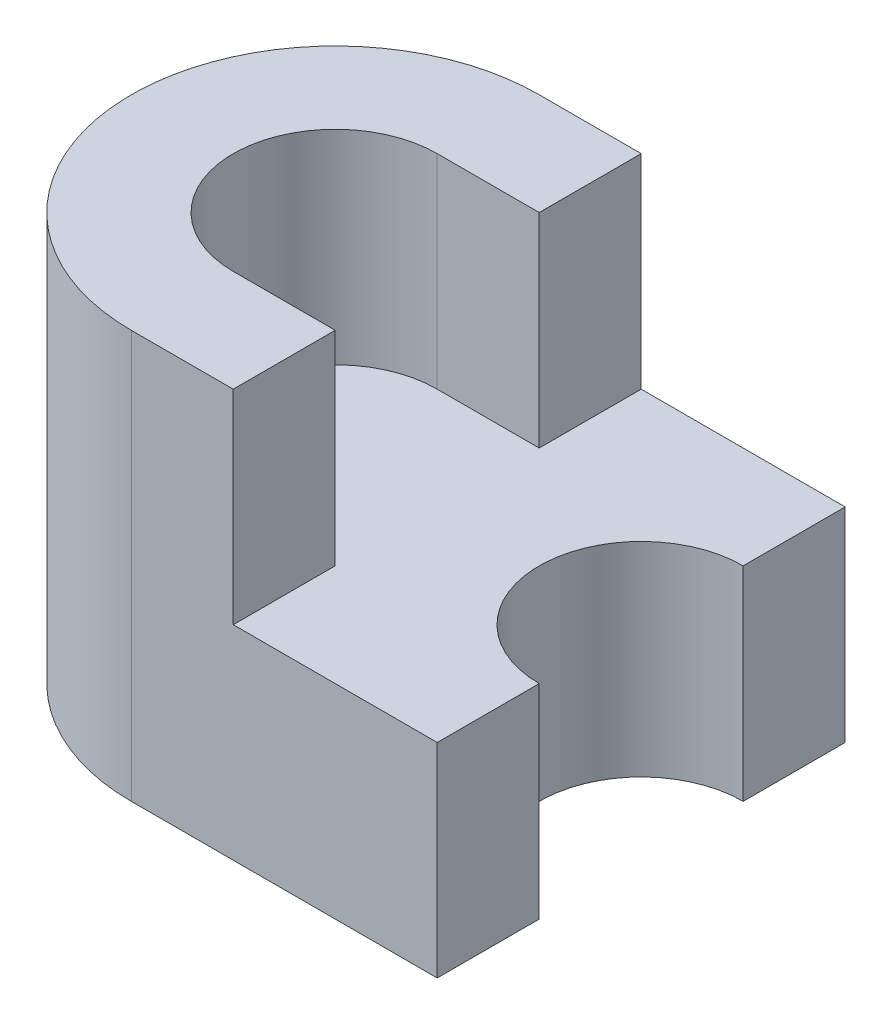
from build123d import *

# Parameters (mm, degrees)
EXTRUDE_1_DEPTH = 10
EXTRUDE_2_DEPTH = 20
SCALE_1_SCALE   = 0.2


with BuildPart() as part:
    # 草圖1 → 填料-伸長1 (new body)
    with BuildSketch(Plane(origin=(0, 0, 0), x_dir=(1, 0, 0), z_dir=(0, 1, 0))):
        with BuildLine():
            Line((15, 10), (0, 10))
            ThreePointArc((0, 10), (-10, 0), (0, -10))
            Line((0, -10), (15, -10))
            Line((15, -10), (15, -5))
            ThreePointArc((15, -5), (10, 0), (15, 5))
            Line((15, 5), (15, 10))
        make_face()
    extrude(amount=EXTRUDE_1_DEPTH)

    # 草圖1<3> → 填料-伸長2 (add)
    with BuildSketch(Plane(origin=(0, 0, 0), x_dir=(1, 0, 0), z_dir=(0, 1, 0))):
        with BuildLine():
            Line((5, 5), (5, 10))
            Line((5, 10), (0, 10))
            ThreePointArc((0, 10), (-10, 0), (0, -10))
            Line((0, -10), (5, -10))
            Line((5, -10), (5, -5))
            Line((5, -5), (0, -5))
            ThreePointArc((0, -5), (-5, 0), (0, 5))
            Line((0, 5), (5, 5))
        make_face()
    extrude(amount=EXTRUDE_2_DEPTH)


with BuildPart() as part_1:
    # 縮放比例1: scaled about (1.057486584, 7.865508049, 0)
    add(part.part.scale(SCALE_1_SCALE).moved(Location((0.845989267, 6.292406439, 0))))


solid = part_1.part
